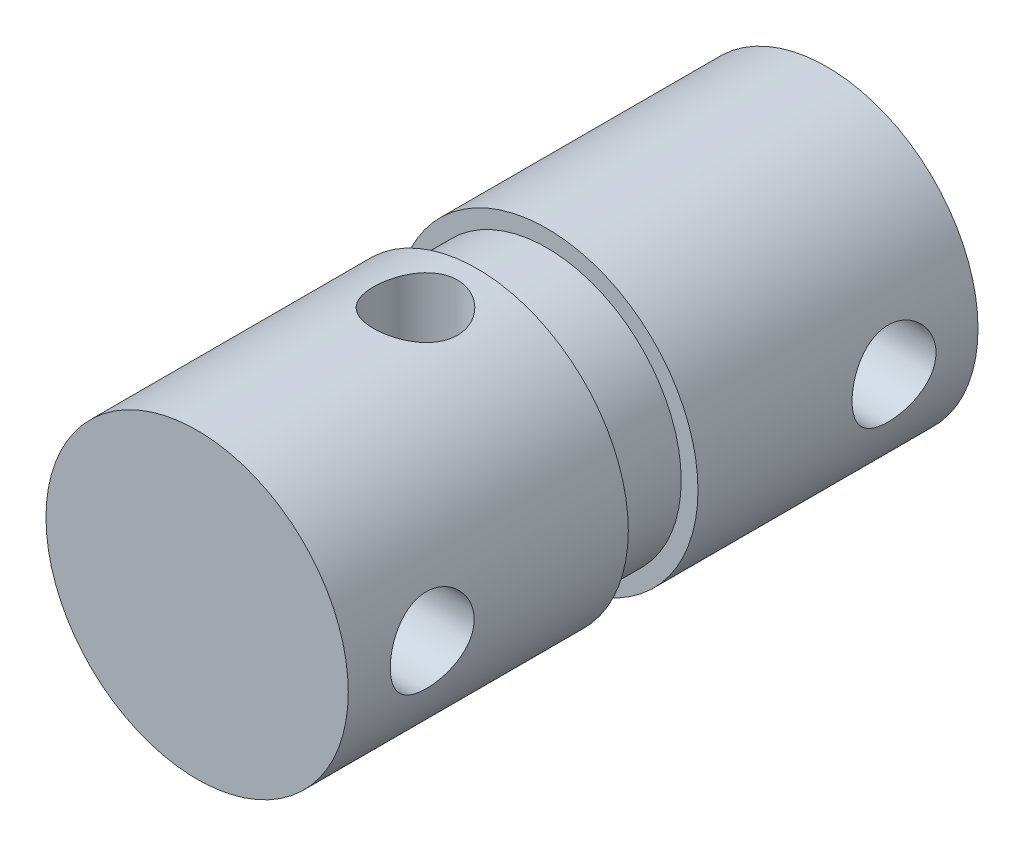
from build123d import *

# Parameters (mm, degrees)
SKETCH3_R               = 1.27
CUT_EXTRUDE1_DEPTH      = 5.572
CUT_EXTRUDE1_DEPTH_BACK = 5.572
SKETCH4_R               = 1.27
CUT_EXTRUDE2_DEPTH      = 5.5720001
CUT_EXTRUDE2_DEPTH_BACK = 5.5720001


with BuildPart() as part:
    # Sketch2 → Revolve1 (revolve)
    with BuildSketch(Plane(origin=(0, 0, 0), x_dir=(1, 0, 0), z_dir=(0, 1, 0))):
        Polygon((0, 0), (0, -19.05), (4.572, -19.05), (4.572, -10.5791), (4.064, -10.5791), (4.064, -8.4709), (4.572, -8.4709), (4.572, 0), align=None)
    revolve(axis=Axis((0, 0, 0), (0, 0, 1)))

    # Sketch3 → Cut-Extrude1 (cut, two sides)
    with BuildSketch(Plane(origin=(0, 0, 0), x_dir=(1, 0, 0), z_dir=(0, 1, 0))) as cut_extrude1_sk:
        with Locations((0, -12.446)):
            Circle(SKETCH3_R)
    extrude(amount=CUT_EXTRUDE1_DEPTH, mode=Mode.SUBTRACT)
    extrude(cut_extrude1_sk.sketch, amount=-CUT_EXTRUDE1_DEPTH_BACK, mode=Mode.SUBTRACT)

    # Sketch4 → Cut-Extrude2 (cut, two sides)
    with BuildSketch(Plane(origin=(0, 0, 0), x_dir=(0, 0, -1), z_dir=(1, 0, 0))) as cut_extrude2_sk:
        with Locations((-2.54, 0)):
            Circle(SKETCH4_R)
        with Locations((-16.51, 0)):
            Circle(SKETCH4_R)
    extrude(amount=CUT_EXTRUDE2_DEPTH, mode=Mode.SUBTRACT)
    extrude(cut_extrude2_sk.sketch, amount=-CUT_EXTRUDE2_DEPTH_BACK, mode=Mode.SUBTRACT)


solid = part.part
